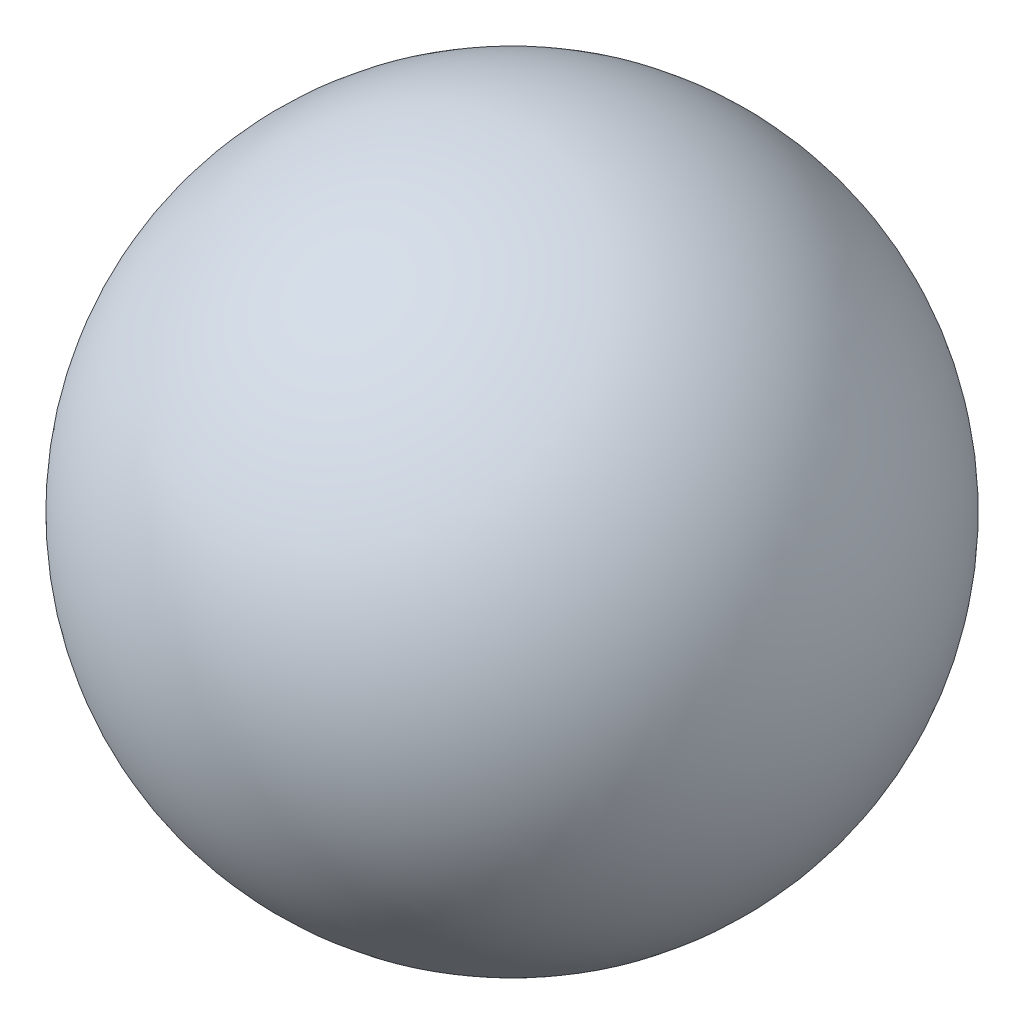
from build123d import *


with BuildPart() as part:
    # Schizzo1 → Rivoluzione1 (revolve)
    with BuildSketch(Plane(origin=(0, 0, 0), x_dir=(0, 0, -1), z_dir=(1, 0, 0))):
        with BuildLine():
            Line((0, -26), (0, 26))
            ThreePointArc((0, 26), (26, 0), (0, -26))
        make_face()
    revolve(axis=Axis((0, -26, 0), (0, 1, 0)))


solid = part.part
